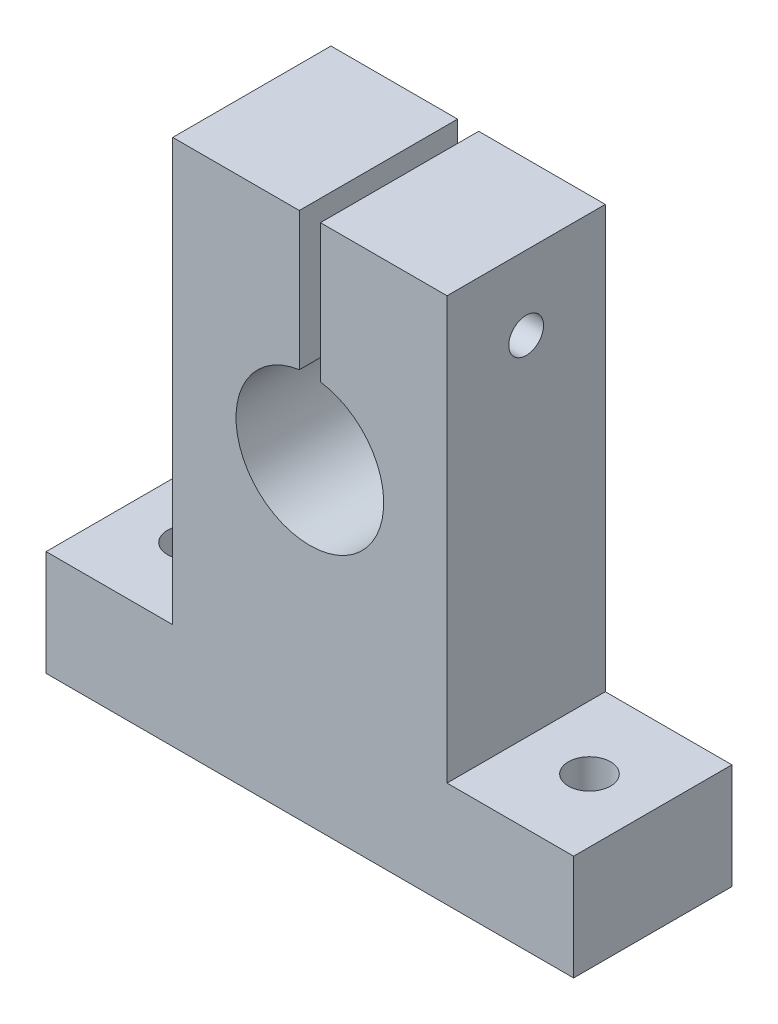
from build123d import *

# Parameters (mm, degrees)
BOSS_EXTRUDE1_DEPTH   = 15
SKETCH5_R             = 2
CUT_EXTRUDE3_DEPTH    = 15
D_GAGEMENT_M41_D      = 4.5
D_GAGEMENT_M41_DEPTH  = 12
TROU_TARAUD_M41_D     = 3.3
TROU_TARAUD_M41_DEPTH = 12


with BuildPart() as part:
    # Sketch1 → Boss-Extrude1 (new body)
    with BuildSketch(Plane.XY):
        with BuildLine():
            Line((-26, 0), (-26, -40))
            Line((-26, -40), (-38, -40))
            Line((-38, -40), (-38, -50))
            Line((-38, -50), (12, -50))
            Line((12, -50), (12, -40))
            Line((12, -40), (0, -40))
            Line((0, -40), (0, 0))
            Line((0, 0), (-12, 0))
            Line((-12, 0), (-12, -13.07179677))
            ThreePointArc((-12, -13.07179677), (-13, -27), (-14, -13.07179677))
            Line((-14, -13.07179677), (-14, 0))
            Line((-14, 0), (-26, 0))
        make_face()
    extrude(amount=BOSS_EXTRUDE1_DEPTH)

    # Sketch5 → Cut-Extrude3 (cut)
    with BuildSketch(Plane(origin=(0, -40, 0), x_dir=(1, 0, 0), z_dir=(0, 1, 0))):
        with Locations((6, -7.5)):
            Circle(SKETCH5_R)
        with Locations((-32, -7.5)):
            Circle(SKETCH5_R)
    extrude(amount=-CUT_EXTRUDE3_DEPTH, mode=Mode.SUBTRACT)

    # Dégagement M41
    with Locations(Plane.ZY.offset(26)):
        with Locations((7.569852971, -7)):
            Hole(D_GAGEMENT_M41_D / 2, depth=D_GAGEMENT_M41_DEPTH)

    # Trou taraudé M41
    with Locations(Plane(origin=(0, 0, 0), x_dir=(0, 0, -1), z_dir=(1, 0, 0))):
        with Locations((-7.5, -7)):
            Hole(TROU_TARAUD_M41_D / 2, depth=TROU_TARAUD_M41_DEPTH)


solid = part.part
